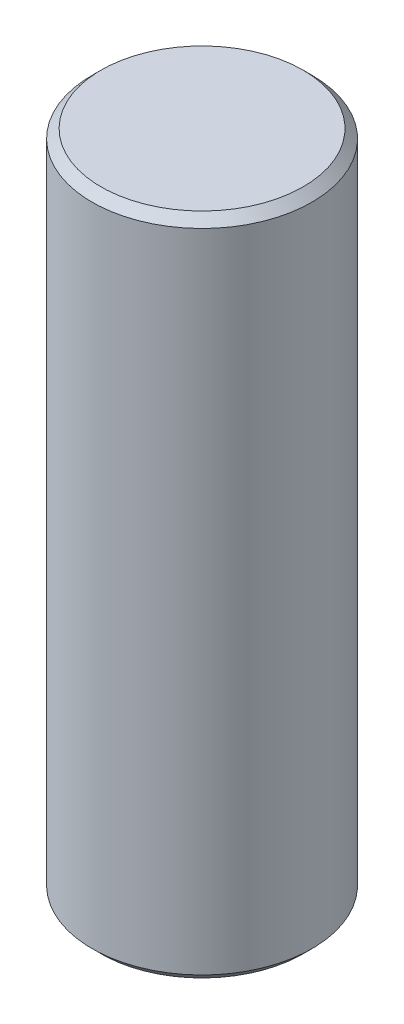
from build123d import *


with BuildPart() as part:
    # Sketch1 → Revolve1 (revolve)
    with BuildSketch(Plane.XY, mode=Mode.PRIVATE) as revolve1_sk:
        Polygon((9.4615, 0.762), (9.4615, 56.388), (8.6995, 57.15), (0, 57.15), (0, 2.286), (4.5339, 2.286), (4.7879, 2.032), (4.7879, 0), (8.6995, 0), align=None)
    revolve(revolve1_sk.sketch.rotate(Axis((0, 0, 0), (0, 1, 0)), 90), axis=Axis((0, 0, 0), (0, 1, 0)))  # turned: the seam where the file's is


solid = part.part
